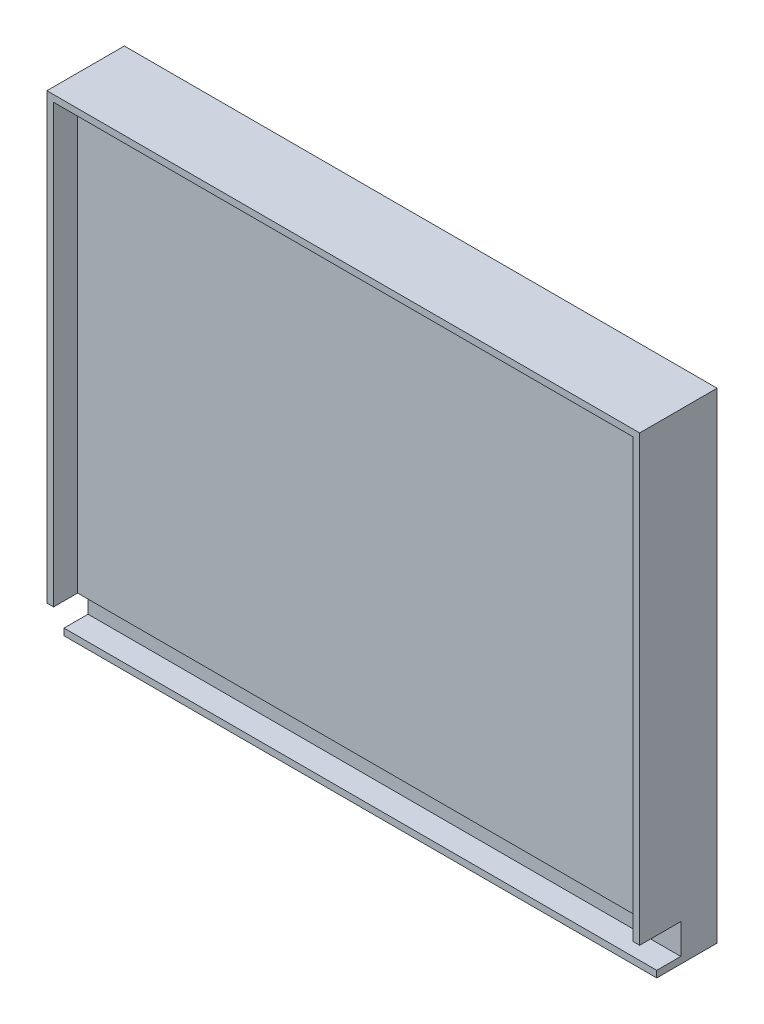
from build123d import *

# Parameters (mm, degrees)
SKETCH1_W            = 281.94
SKETCH1_H            = 228.6
BOSS_EXTRUDE2_DEPTH  = 25.4
SKETCH3_W            = 281.94
SKETCH3_H            = 17.526
CUT_EXTRUDE1_DEPTH   = 8.128
SKETCH4_W            = 11.43
SKETCH4_H            = 211.074
BOSS_EXTRUDE4_DEPTH  = 3.175
SKETCH5_W            = 278.765
SKETCH5_H            = 11.43
BOSS_EXTRUDE9_DEPTH  = 3.175
SKETCH9_W            = 11.43
SKETCH9_H            = 207.899
BOSS_EXTRUDE10_DEPTH = 3.175
SKETCH8_W            = 281.94
SKETCH8_H            = 11.43
BOSS_EXTRUDE11_DEPTH = 3.175


with BuildPart() as part:
    # Sketch1 → Boss-Extrude2 (new body)
    with BuildSketch(Plane.XY):
        with Locations((72.606829268, 16.339634146)):
            Rectangle(SKETCH1_W, SKETCH1_H)
    extrude(amount=BOSS_EXTRUDE2_DEPTH)

    # Sketch3 → Cut-Extrude1 (cut)
    with BuildSketch(Plane.XY.offset(25.4)):
        with Locations((72.606829268, -89.197365854)):
            Rectangle(SKETCH3_W, SKETCH3_H)
    extrude(amount=-CUT_EXTRUDE1_DEPTH, mode=Mode.SUBTRACT)



with BuildPart() as body_2:
    # Sketch4 → Boss-Extrude4 (new body)
    with BuildSketch(Plane.ZY.offset(68.363170732)):
        with Locations((31.115, 25.102634146)):
            Rectangle(SKETCH4_W, SKETCH4_H)
    extrude(amount=-BOSS_EXTRUDE4_DEPTH)


with BuildPart() as part_1:
    add(part.part)

    add(body_2.part)  # Boss-Extrude9 merges body 2
    # Sketch5 → Boss-Extrude9 (add)
    with BuildSketch(Plane(origin=(0, 130.639634146, 0), x_dir=(1, 0, 0), z_dir=(0, 1, 0))):
        with Locations((74.194329268, -31.115)):
            Rectangle(SKETCH5_W, SKETCH5_H)
    extrude(amount=-BOSS_EXTRUDE9_DEPTH)

    # Sketch9 → Boss-Extrude10 (add)
    with BuildSketch(Plane(origin=(213.576829268, 0, 0), x_dir=(0, 0, -1), z_dir=(1, 0, 0))):
        with Locations((-31.115, 23.515134146)):
            Rectangle(SKETCH9_W, SKETCH9_H)
    extrude(amount=-BOSS_EXTRUDE10_DEPTH)


with BuildPart() as body_2_2:
    # Sketch8 → Boss-Extrude11 (new body)
    with BuildSketch(Plane.XZ.offset(97.960365854)):
        with Locations((72.606829268, 22.987)):
            Rectangle(SKETCH8_W, SKETCH8_H)
    extrude(amount=-BOSS_EXTRUDE11_DEPTH)

    # Combine1: union part
    add(part_1.part)


solid = body_2_2.part
